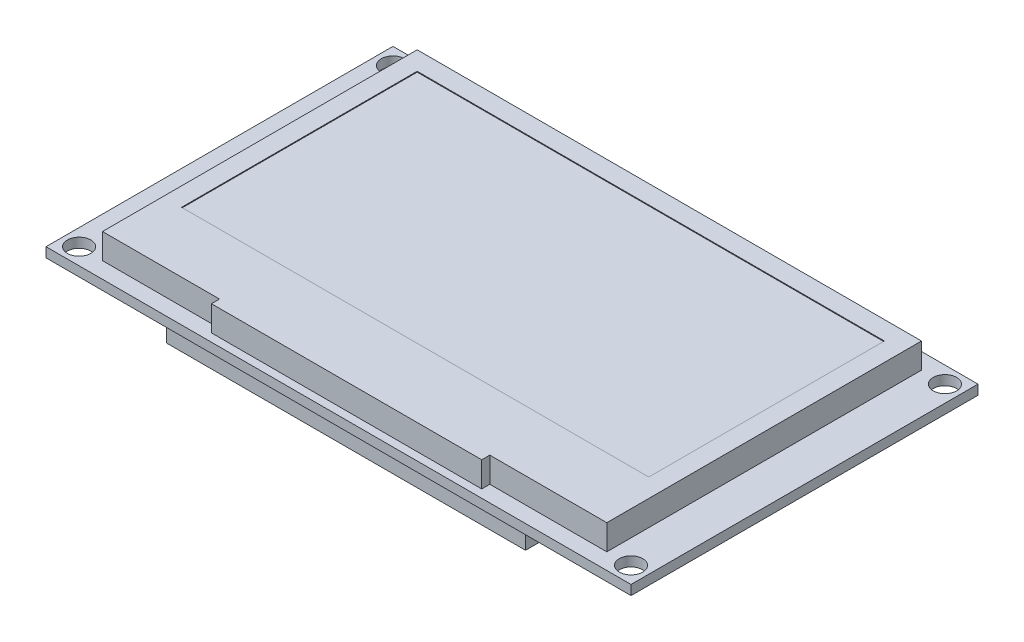
from build123d import *

# Parameters (mm, degrees)
SKETCH1_W           = 72.5
SKETCH1_H           = 43
SKETCH1_R           = 1.45
SKETCH1_R_2         = 0.5
BOSS_EXTRUDE1_DEPTH = 1.2
SKETCH2_W           = 44.5
SKETCH2_H           = 41.146019014
BOSS_EXTRUDE2_DEPTH = 2.6
BOSS_EXTRUDE3_DEPTH = 3.13
SKETCH4_W           = 57.9
SKETCH4_H           = 29.2
CUT_EXTRUDE1_DEPTH  = 0.1


with BuildPart() as part:
    # Sketch1 → Boss-Extrude1 (new body)
    with BuildSketch(Plane(origin=(0, 0, 0), x_dir=(1, 0, 0), z_dir=(0, 1, 0))):
        Rectangle(SKETCH1_W, SKETCH1_H)
        with Locations((-34.2, 19.45)):
            Circle(SKETCH1_R, mode=Mode.SUBTRACT)
        with Locations((-33.75, 7.62)):
            Circle(SKETCH1_R_2, mode=Mode.SUBTRACT)
        with Locations((-33.75, 5.08)):
            Circle(SKETCH1_R_2, mode=Mode.SUBTRACT)
        with Locations((-33.75, 2.54)):
            Circle(SKETCH1_R_2, mode=Mode.SUBTRACT)
        with Locations((-33.75, 0)):
            Circle(SKETCH1_R_2, mode=Mode.SUBTRACT)
        with Locations((-33.75, -2.54)):
            Circle(SKETCH1_R_2, mode=Mode.SUBTRACT)
        with Locations((-33.75, -5.08)):
            Circle(SKETCH1_R_2, mode=Mode.SUBTRACT)
        with Locations((-33.75, -7.62)):
            Circle(SKETCH1_R_2, mode=Mode.SUBTRACT)
        with Locations((-34.2, -19.45)):
            Circle(SKETCH1_R, mode=Mode.SUBTRACT)
        with Locations((34.2, 19.45)):
            Circle(SKETCH1_R, mode=Mode.SUBTRACT)
        with Locations((34.2, -19.45)):
            Circle(SKETCH1_R, mode=Mode.SUBTRACT)
    extrude(amount=-BOSS_EXTRUDE1_DEPTH)

    # Sketch2 → Boss-Extrude2 (add)
    with BuildSketch(Plane.XZ.offset(1.2)):
        Rectangle(SKETCH2_W, SKETCH2_H)
    extrude(amount=BOSS_EXTRUDE2_DEPTH)

    # Sketch3 → Boss-Extrude3 (add)
    with BuildSketch(Plane(origin=(0, 0, 0), x_dir=(1, 0, 0), z_dir=(0, 1, 0))):
        Polygon((-16.75, -19.5), (-16.75, -20.5), (16.75, -20.5), (16.75, -19.5), (31.25, -19.5), (31.25, 19.5), (-31.25, 19.5), (-31.25, -19.5), align=None)
    extrude(amount=BOSS_EXTRUDE3_DEPTH)

    # Sketch4 → Cut-Extrude1 (cut)
    with BuildSketch(Plane(origin=(0, 3.13, 0), x_dir=(1, 0, 0), z_dir=(0, 1, 0))):
        with Locations((0, 2.6)):
            Rectangle(SKETCH4_W, SKETCH4_H)
    extrude(amount=-CUT_EXTRUDE1_DEPTH, mode=Mode.SUBTRACT)


solid = part.part
